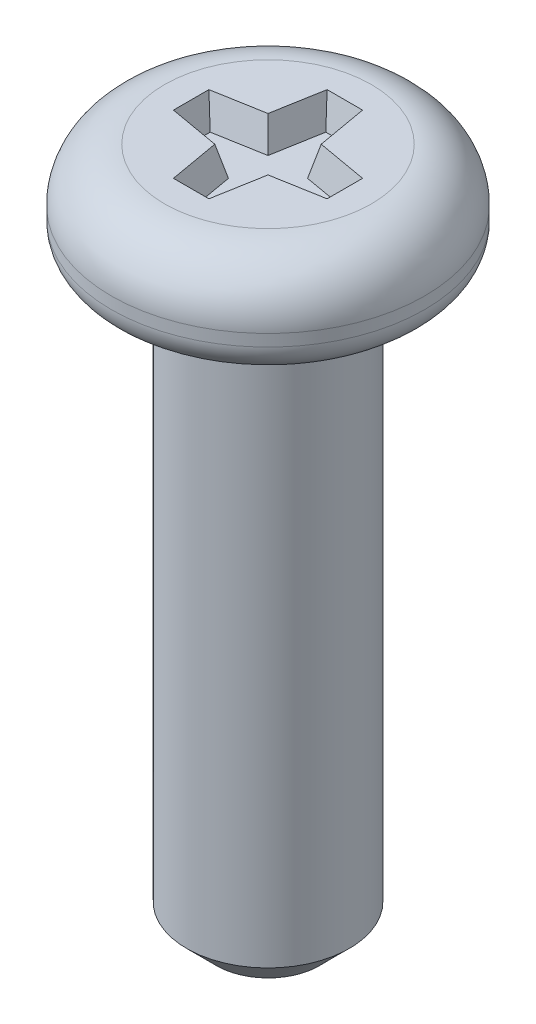
from build123d import *

# Parameters (mm, degrees)
CUT_EXTRUDE1_DEPTH = 0.5
CUT_EXTRUDE1_TAPER = 15


with BuildPart() as part:
    # Sketch1 → Revolve1 (revolve)
    with BuildSketch(Plane.XY):
        with BuildLine():
            Line((0, -11.6), (0.875, -11.6))
            Line((0.875, -11.6), (1.375, -11.1))
            Line((1.375, -11.1), (1.375, -1.75))
            ThreePointArc((1.375, -1.75), (1.418933983, -1.643933983), (1.525, -1.6))
            Line((1.525, -1.6), (2.15, -1.6))
            ThreePointArc((2.15, -1.6), (2.503553391, -1.453553391), (2.65, -1.1))
            Line((2.65, -1.1), (2.65, -0.9))
            ThreePointArc((2.65, -0.9), (2.386396103, -0.263603897), (1.75, 0))
            Line((1.75, 0), (0, 0))
            Line((0, 0), (0, -11.6))
        make_face()
    revolve(axis=Axis((0, 0, 0), (0, -1, 0)))

    # Sketch2 → Cut-Extrude1 (cut)
    with BuildSketch(Plane(origin=(0, 0, 0), x_dir=(1, 0, 0), z_dir=(0, 1, 0))):
        Polygon((-0.300122066, 1.3), (-0.45, 0.45), (-1.3, 0.300122066), (-1.3, -0.300122066), (-0.45, -0.45), (-0.300122066, -1.3), (0.300122066, -1.3), (0.45, -0.45), (1.3, -0.300122066), (1.3, 0.300122066), (0.45, 0.45), (0.300122066, 1.3), align=None)
    extrude(amount=-CUT_EXTRUDE1_DEPTH, taper=CUT_EXTRUDE1_TAPER, mode=Mode.SUBTRACT)


solid = part.part
